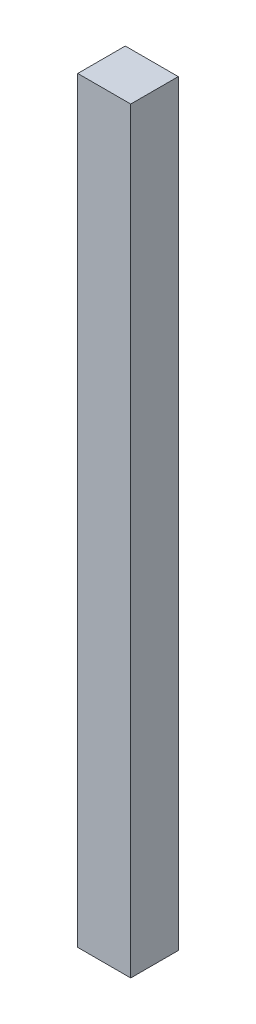
from build123d import *

# Parameters (mm, degrees)
SCHIZZO1_W                   = 7
SCHIZZO1_H                   = 100
ESTRUSIONE_ESTRUSIONE1_DEPTH = 6.28


with BuildPart() as part:
    # Schizzo1 → Estrusione-Estrusione1 (new body)
    with BuildSketch(Plane.XY):
        with Locations((3.5, 50)):
            Rectangle(SCHIZZO1_W, SCHIZZO1_H)
    extrude(amount=ESTRUSIONE_ESTRUSIONE1_DEPTH)


solid = part.part
